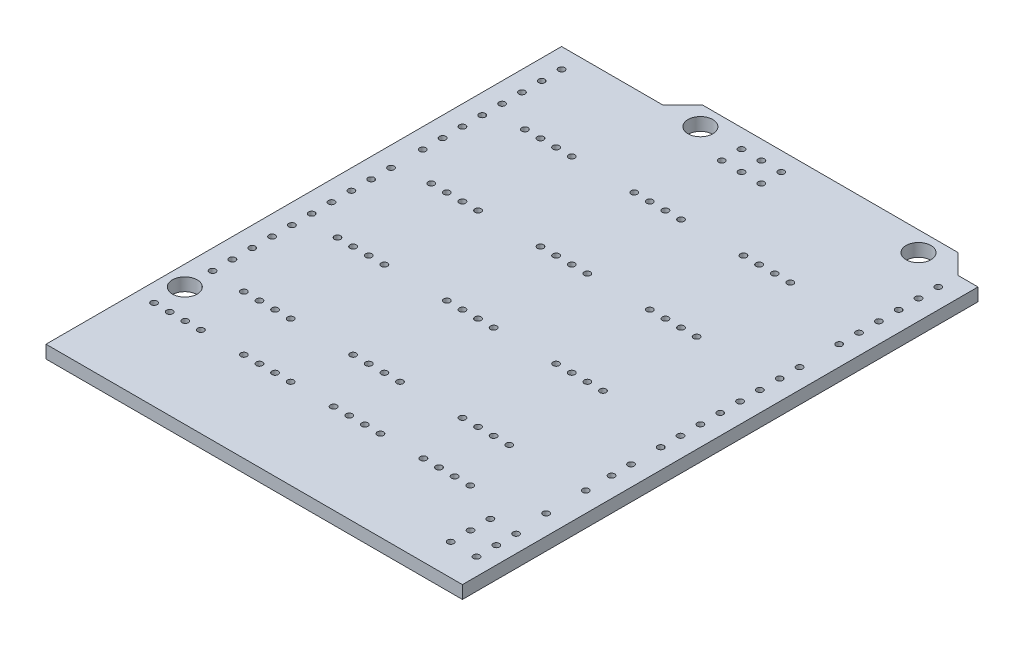
from build123d import *

# Parameters (mm, degrees)
SKETCH1_R                             = 1.5875
BOSS_EXTRUDE1_DEPTH                   = 1.65
SKETCH2_R                             = 0.4
CUT_EXTRUDE1_DEPTH                    = 1.65
SKETCH3_R                             = 0.4
CUT_EXTRUDE2_DEPTH                    = 1.65
LPATTERN1_COUNT                       = 15
LPATTERN1_PITCH                       = 2.54
SKETCH4_R                             = 0.4
CUT_EXTRUDE3_DEPTH                    = 1.65
LPATTERN2_COUNT                       = 10
LPATTERN2_PITCH                       = 2.54
LPATTERN3_COUNT                       = 8
LPATTERN3_PITCH                       = 2.54
SKETCH5_R                             = 0.4
CUT_EXTRUDE4_DEPTH                    = 10
ESQUISSE1_R                           = 0.4
ENL_V_MAT_EXTRU_1_DEPTH               = 10
R_P_TITION_LIN_AIRE1_COUNT            = 4
R_P_TITION_LIN_AIRE1_PITCH            = 2
R_P_TITION_LIN_AIRE1_COUNT_DIR2       = 4
R_P_TITION_LIN_AIRE1_PITCH_DIR2       = 11.5
ESQUISSE2_R                           = 0.4
ENL_V_MAT_EXTRU_2_DEPTH               = 10
R_P_TITION_LIN_AIRE2_COUNT            = 4
R_P_TITION_LIN_AIRE2_PITCH            = 2
R_P_TITION_LIN_AIRE2_COUNT_DIR2       = 3
R_P_TITION_LIN_AIRE2_PITCH_DIR2       = 14
R_P_TITION_LIN_AIRE3_COUNT            = 4
R_P_TITION_LIN_AIRE3_PITCH            = 12
R_P_TITION_LIN_AIRE3_COPY_1_SKETCH_R  = 0.4
R_P_TITION_LIN_AIRE3_COPY_1_DEPTH     = 10
R_P_TITION_LIN_AIRE3_COPY_2_SKETCH_R  = 0.4
R_P_TITION_LIN_AIRE3_COPY_2_DEPTH     = 10
R_P_TITION_LIN_AIRE3_COPY_3_SKETCH_R  = 0.4
R_P_TITION_LIN_AIRE3_COPY_3_DEPTH     = 10
R_P_TITION_LIN_AIRE3_COPY_4_SKETCH_R  = 0.4
R_P_TITION_LIN_AIRE3_COPY_4_DEPTH     = 10
R_P_TITION_LIN_AIRE3_COPY_5_SKETCH_R  = 0.4
R_P_TITION_LIN_AIRE3_COPY_5_DEPTH     = 10
R_P_TITION_LIN_AIRE3_COPY_6_SKETCH_R  = 0.4
R_P_TITION_LIN_AIRE3_COPY_6_DEPTH     = 10
R_P_TITION_LIN_AIRE3_COPY_7_SKETCH_R  = 0.4
R_P_TITION_LIN_AIRE3_COPY_7_DEPTH     = 10
R_P_TITION_LIN_AIRE3_COPY_8_SKETCH_R  = 0.4
R_P_TITION_LIN_AIRE3_COPY_8_DEPTH     = 10
R_P_TITION_LIN_AIRE3_COPY_9_SKETCH_R  = 0.4
R_P_TITION_LIN_AIRE3_COPY_9_DEPTH     = 10
R_P_TITION_LIN_AIRE3_COPY_10_SKETCH_R = 0.4
R_P_TITION_LIN_AIRE3_COPY_10_DEPTH    = 10
R_P_TITION_LIN_AIRE3_COPY_11_SKETCH_R = 0.4
R_P_TITION_LIN_AIRE3_COPY_11_DEPTH    = 10
R_P_TITION_LIN_AIRE3_COPY_12_SKETCH_R = 0.4
R_P_TITION_LIN_AIRE3_COPY_12_DEPTH    = 10
R_P_TITION_LIN_AIRE3_COPY_13_SKETCH_R = 0.4
R_P_TITION_LIN_AIRE3_COPY_13_DEPTH    = 10
R_P_TITION_LIN_AIRE3_COPY_14_SKETCH_R = 0.4
R_P_TITION_LIN_AIRE3_COPY_14_DEPTH    = 10
R_P_TITION_LIN_AIRE3_COPY_15_SKETCH_R = 0.4
R_P_TITION_LIN_AIRE3_COPY_15_DEPTH    = 10
R_P_TITION_LIN_AIRE3_COPY_16_SKETCH_R = 0.4
R_P_TITION_LIN_AIRE3_COPY_16_DEPTH    = 10
R_P_TITION_LIN_AIRE3_COPY_17_SKETCH_R = 0.4
R_P_TITION_LIN_AIRE3_COPY_17_DEPTH    = 10
R_P_TITION_LIN_AIRE3_COPY_18_SKETCH_R = 0.4
R_P_TITION_LIN_AIRE3_COPY_18_DEPTH    = 10
R_P_TITION_LIN_AIRE3_COPY_19_SKETCH_R = 0.4
R_P_TITION_LIN_AIRE3_COPY_19_DEPTH    = 10
R_P_TITION_LIN_AIRE3_COPY_20_SKETCH_R = 0.4
R_P_TITION_LIN_AIRE3_COPY_20_DEPTH    = 10
R_P_TITION_LIN_AIRE3_COPY_21_SKETCH_R = 0.4
R_P_TITION_LIN_AIRE3_COPY_21_DEPTH    = 10
R_P_TITION_LIN_AIRE3_COPY_22_SKETCH_R = 0.4
R_P_TITION_LIN_AIRE3_COPY_22_DEPTH    = 10
R_P_TITION_LIN_AIRE3_COPY_23_SKETCH_R = 0.4
R_P_TITION_LIN_AIRE3_COPY_23_DEPTH    = 10
R_P_TITION_LIN_AIRE3_COPY_24_SKETCH_R = 0.4
R_P_TITION_LIN_AIRE3_COPY_24_DEPTH    = 10
R_P_TITION_LIN_AIRE3_COPY_25_SKETCH_R = 0.4
R_P_TITION_LIN_AIRE3_COPY_25_DEPTH    = 10
R_P_TITION_LIN_AIRE3_COPY_26_SKETCH_R = 0.4
R_P_TITION_LIN_AIRE3_COPY_26_DEPTH    = 10
R_P_TITION_LIN_AIRE3_COPY_27_SKETCH_R = 0.4
R_P_TITION_LIN_AIRE3_COPY_27_DEPTH    = 10
R_P_TITION_LIN_AIRE3_COPY_28_SKETCH_R = 0.4
R_P_TITION_LIN_AIRE3_COPY_28_DEPTH    = 10
R_P_TITION_LIN_AIRE3_COPY_29_SKETCH_R = 0.4
R_P_TITION_LIN_AIRE3_COPY_29_DEPTH    = 10
R_P_TITION_LIN_AIRE3_COPY_30_SKETCH_R = 0.4
R_P_TITION_LIN_AIRE3_COPY_30_DEPTH    = 10
R_P_TITION_LIN_AIRE3_COPY_31_SKETCH_R = 0.4
R_P_TITION_LIN_AIRE3_COPY_31_DEPTH    = 10
R_P_TITION_LIN_AIRE3_COPY_32_SKETCH_R = 0.4
R_P_TITION_LIN_AIRE3_COPY_32_DEPTH    = 10
R_P_TITION_LIN_AIRE3_COPY_33_SKETCH_R = 0.4
R_P_TITION_LIN_AIRE3_COPY_33_DEPTH    = 10


with BuildPart() as part:
    # Sketch1 → Boss-Extrude1 (new body)
    with BuildSketch(Plane(origin=(0, 0, 0), x_dir=(1, 0, 0), z_dir=(0, 1, 0))):
        Polygon((0, 0), (-53.34, 0), (-53.34, 66.04), (-40.386, 66.04), (-37.846, 68.58), (-5.08, 68.58), (-2.54, 66.04), (0, 66.04), align=None)
        with Locations(Location((-7.62, 66.04, 0), (0, 0, 270))):  # turned: the seam where the file's is
            Circle(SKETCH1_R, mode=Mode.SUBTRACT)
        with Locations(Location((-35.56, 66.04, 0), (0, 0, 270))):  # turned: the seam where the file's is
            Circle(SKETCH1_R, mode=Mode.SUBTRACT)
        with Locations(Location((-50.8, 15.24, 0), (0, 0, 270))):  # turned: the seam where the file's is
            Circle(SKETCH1_R, mode=Mode.SUBTRACT)
    extrude(amount=-BOSS_EXTRUDE1_DEPTH)

    # Sketch2 → Cut-Extrude1 (cut)
    with BuildSketch(Plane(origin=(0, 0, 0), x_dir=(1, 0, 0), z_dir=(0, 1, 0))):
        with Locations(Location((-2.54, 27.94, 0), (0, 0, 270))):  # turned: the seam where the file's is
            Circle(SKETCH2_R)
    cut_extrude1 = extrude(amount=-CUT_EXTRUDE1_DEPTH, mode=Mode.SUBTRACT)

    # Sketch3 → Cut-Extrude2 (cut)
    with BuildSketch(Plane(origin=(0, 0, 0), x_dir=(1, 0, 0), z_dir=(0, 1, 0))):
        with Locations(Location((-50.8, 18.796, 0), (0, 0, 270))):  # turned: the seam where the file's is
            Circle(SKETCH3_R)
    cut_extrude2 = extrude(amount=-CUT_EXTRUDE2_DEPTH, mode=Mode.SUBTRACT)

    # LPattern1: Cut-Extrude1 ×15, 1 skipped
    with Locations(*[(0, 0, -i * LPATTERN1_PITCH) for i in range(1, LPATTERN1_COUNT) if i not in (8,)]):
        add(cut_extrude1, mode=Mode.SUBTRACT)

    # Sketch4 → Cut-Extrude3 (cut)
    with BuildSketch(Plane(origin=(0, 0, 0), x_dir=(1, 0, 0), z_dir=(0, 1, 0))):
        with Locations(Location((-50.8, 45.72, 0), (0, 0, 270))):  # turned: the seam where the file's is
            Circle(SKETCH4_R)
    cut_extrude3 = extrude(amount=-CUT_EXTRUDE3_DEPTH, mode=Mode.SUBTRACT)

    # LPattern2: Cut-Extrude2 ×10
    with Locations(*[(0, 0, -i * LPATTERN2_PITCH) for i in range(1, LPATTERN2_COUNT)]):
        add(cut_extrude2, mode=Mode.SUBTRACT)

    # LPattern3: Cut-Extrude3 ×8
    with Locations(*[(0, 0, -i * LPATTERN3_PITCH) for i in range(1, LPATTERN3_COUNT)]):
        add(cut_extrude3, mode=Mode.SUBTRACT)

    # Sketch5 → Cut-Extrude4 (cut)
    with BuildSketch(Plane(origin=(0, 0, 0), x_dir=(1, 0, 0), z_dir=(0, 1, 0))):
        with Locations(Location((-30.43, 66.18, 0), (0, 0, 270))):  # turned: the seam where the file's is
            Circle(SKETCH5_R)
        with Locations(Location((-27.89, 66.18, 0), (0, 0, 270))):  # turned: the seam where the file's is
            Circle(SKETCH5_R)
        with Locations(Location((-25.35, 66.18, 0), (0, 0, 270))):  # turned: the seam where the file's is
            Circle(SKETCH5_R)
        with Locations(Location((-25.35, 63.64, 0), (0, 0, 270))):  # turned: the seam where the file's is
            Circle(SKETCH5_R)
        with Locations(Location((-27.89, 63.64, 0), (0, 0, 270))):  # turned: the seam where the file's is
            Circle(SKETCH5_R)
        with Locations(Location((-30.43, 63.64, 0), (0, 0, 270))):  # turned: the seam where the file's is
            Circle(SKETCH5_R)
        with Locations(Location((-5.5, 4, 0), (0, 0, 270))):  # turned: the seam where the file's is
            Circle(SKETCH5_R)
        with Locations(Location((-5.5, 6.54, 0), (0, 0, 270))):  # turned: the seam where the file's is
            Circle(SKETCH5_R)
        with Locations(Location((-5.5, 9.08, 0), (0, 0, 270))):  # turned: the seam where the file's is
            Circle(SKETCH5_R)
        with Locations(Location((-2.2, 9.08, 0), (0, 0, 270))):  # turned: the seam where the file's is
            Circle(SKETCH5_R)
        with Locations(Location((-2.2, 6.54, 0), (0, 0, 270))):  # turned: the seam where the file's is
            Circle(SKETCH5_R)
        with Locations(Location((-2.2, 4, 0), (0, 0, 270))):  # turned: the seam where the file's is
            Circle(SKETCH5_R)
        with Locations(Location((-2.54, 24.14, 0), (0, 0, 270))):  # turned: the seam where the file's is
            Circle(SKETCH5_R)
        with Locations(Location((-2.54, 21.64, 0), (0, 0, 270))):  # turned: the seam where the file's is
            Circle(SKETCH5_R)
        with Locations(Location((-2.54, 18.34, 0), (0, 0, 270))):  # turned: the seam where the file's is
            Circle(SKETCH5_R)
        with Locations(Location((-2.54, 13.26, 0), (0, 0, 270))):  # turned: the seam where the file's is
            Circle(SKETCH5_R)
    extrude(amount=-CUT_EXTRUDE4_DEPTH, mode=Mode.SUBTRACT)

    # Esquisse1 → Enlèv. mat.-Extru.1 (cut)
    with BuildSketch(Plane.XZ.offset(1.65)):
        with Locations(Location((-10.5, -11.5, 0), (0, 0, 270))):  # turned: the seam where the file's is
            Circle(ESQUISSE1_R)
    enl_v_mat_extru_1 = extrude(amount=-ENL_V_MAT_EXTRU_1_DEPTH, mode=Mode.SUBTRACT)

    # Répétition linéaire1: Enl_v. mat.-Extru.1 4 × 4
    with Locations(*[Vector(-1, 0, 0) * (i * R_P_TITION_LIN_AIRE1_PITCH) + Vector(-1, 0, 0) * (j * R_P_TITION_LIN_AIRE1_PITCH_DIR2) for i in range(R_P_TITION_LIN_AIRE1_COUNT) for j in range(R_P_TITION_LIN_AIRE1_COUNT_DIR2) if (i, j) != (0, 0)]):
        add(enl_v_mat_extru_1, mode=Mode.SUBTRACT)

    # Esquisse2 → Enlèv. mat.-Extru.2 (cut)
    with BuildSketch(Plane.XZ.offset(1.65)):
        with Locations(Location((-12.5, -18.5, 0), (0, 0, 270))):  # turned: the seam where the file's is
            Circle(ESQUISSE2_R)
    enl_v_mat_extru_2 = extrude(amount=-ENL_V_MAT_EXTRU_2_DEPTH, mode=Mode.SUBTRACT)

    # Répétition linéaire2: Enl_v. mat.-Extru.2 4 × 3
    with Locations(*[Vector(-1, 0, 0) * (i * R_P_TITION_LIN_AIRE2_PITCH) + Vector(-1, 0, 0) * (j * R_P_TITION_LIN_AIRE2_PITCH_DIR2) for i in range(R_P_TITION_LIN_AIRE2_COUNT) for j in range(R_P_TITION_LIN_AIRE2_COUNT_DIR2) if (i, j) != (0, 0)]):
        add(enl_v_mat_extru_2, mode=Mode.SUBTRACT)

    # Répétition linéaire3: Enlèv. mat.-Extru.2 ×4
    with Locations(*[(0, 0, -i * R_P_TITION_LIN_AIRE3_PITCH) for i in range(1, R_P_TITION_LIN_AIRE3_COUNT)]):
        add(enl_v_mat_extru_2, mode=Mode.SUBTRACT)

    # Répétition linéaire3 copy 1 sketch → Répétition linéaire3 copy 1 (cut)
    with BuildSketch(Plane(origin=(-14, -1.65, -12), x_dir=(1, 0, 0), z_dir=(0, -1, 0))):
        with Locations(Location((-12.5, -18.5, 0), (0, 0, 270))):  # turned: the seam where the file's is
            Circle(R_P_TITION_LIN_AIRE3_COPY_1_SKETCH_R)
    extrude(amount=-R_P_TITION_LIN_AIRE3_COPY_1_DEPTH, mode=Mode.SUBTRACT)

    # Répétition linéaire3 copy 2 sketch → Répétition linéaire3 copy 2 (cut)
    with BuildSketch(Plane(origin=(-14, -1.65, -24), x_dir=(1, 0, 0), z_dir=(0, -1, 0))):
        with Locations(Location((-12.5, -18.5, 0), (0, 0, 270))):  # turned: the seam where the file's is
            Circle(R_P_TITION_LIN_AIRE3_COPY_2_SKETCH_R)
    extrude(amount=-R_P_TITION_LIN_AIRE3_COPY_2_DEPTH, mode=Mode.SUBTRACT)

    # Répétition linéaire3 copy 3 sketch → Répétition linéaire3 copy 3 (cut)
    with BuildSketch(Plane(origin=(-14, -1.65, -36), x_dir=(1, 0, 0), z_dir=(0, -1, 0))):
        with Locations(Location((-12.5, -18.5, 0), (0, 0, 270))):  # turned: the seam where the file's is
            Circle(R_P_TITION_LIN_AIRE3_COPY_3_SKETCH_R)
    extrude(amount=-R_P_TITION_LIN_AIRE3_COPY_3_DEPTH, mode=Mode.SUBTRACT)

    # Répétition linéaire3 copy 4 sketch → Répétition linéaire3 copy 4 (cut)
    with BuildSketch(Plane(origin=(-28, -1.65, -12), x_dir=(1, 0, 0), z_dir=(0, -1, 0))):
        with Locations(Location((-12.5, -18.5, 0), (0, 0, 270))):  # turned: the seam where the file's is
            Circle(R_P_TITION_LIN_AIRE3_COPY_4_SKETCH_R)
    extrude(amount=-R_P_TITION_LIN_AIRE3_COPY_4_DEPTH, mode=Mode.SUBTRACT)

    # Répétition linéaire3 copy 5 sketch → Répétition linéaire3 copy 5 (cut)
    with BuildSketch(Plane(origin=(-28, -1.65, -24), x_dir=(1, 0, 0), z_dir=(0, -1, 0))):
        with Locations(Location((-12.5, -18.5, 0), (0, 0, 270))):  # turned: the seam where the file's is
            Circle(R_P_TITION_LIN_AIRE3_COPY_5_SKETCH_R)
    extrude(amount=-R_P_TITION_LIN_AIRE3_COPY_5_DEPTH, mode=Mode.SUBTRACT)

    # Répétition linéaire3 copy 6 sketch → Répétition linéaire3 copy 6 (cut)
    with BuildSketch(Plane(origin=(-28, -1.65, -36), x_dir=(1, 0, 0), z_dir=(0, -1, 0))):
        with Locations(Location((-12.5, -18.5, 0), (0, 0, 270))):  # turned: the seam where the file's is
            Circle(R_P_TITION_LIN_AIRE3_COPY_6_SKETCH_R)
    extrude(amount=-R_P_TITION_LIN_AIRE3_COPY_6_DEPTH, mode=Mode.SUBTRACT)

    # Répétition linéaire3 copy 7 sketch → Répétition linéaire3 copy 7 (cut)
    with BuildSketch(Plane(origin=(-2, -1.65, -12), x_dir=(1, 0, 0), z_dir=(0, -1, 0))):
        with Locations(Location((-12.5, -18.5, 0), (0, 0, 270))):  # turned: the seam where the file's is
            Circle(R_P_TITION_LIN_AIRE3_COPY_7_SKETCH_R)
    extrude(amount=-R_P_TITION_LIN_AIRE3_COPY_7_DEPTH, mode=Mode.SUBTRACT)

    # Répétition linéaire3 copy 8 sketch → Répétition linéaire3 copy 8 (cut)
    with BuildSketch(Plane(origin=(-2, -1.65, -24), x_dir=(1, 0, 0), z_dir=(0, -1, 0))):
        with Locations(Location((-12.5, -18.5, 0), (0, 0, 270))):  # turned: the seam where the file's is
            Circle(R_P_TITION_LIN_AIRE3_COPY_8_SKETCH_R)
    extrude(amount=-R_P_TITION_LIN_AIRE3_COPY_8_DEPTH, mode=Mode.SUBTRACT)

    # Répétition linéaire3 copy 9 sketch → Répétition linéaire3 copy 9 (cut)
    with BuildSketch(Plane(origin=(-2, -1.65, -36), x_dir=(1, 0, 0), z_dir=(0, -1, 0))):
        with Locations(Location((-12.5, -18.5, 0), (0, 0, 270))):  # turned: the seam where the file's is
            Circle(R_P_TITION_LIN_AIRE3_COPY_9_SKETCH_R)
    extrude(amount=-R_P_TITION_LIN_AIRE3_COPY_9_DEPTH, mode=Mode.SUBTRACT)

    # Répétition linéaire3 copy 10 sketch → Répétition linéaire3 copy 10 (cut)
    with BuildSketch(Plane(origin=(-16, -1.65, -12), x_dir=(1, 0, 0), z_dir=(0, -1, 0))):
        with Locations(Location((-12.5, -18.5, 0), (0, 0, 270))):  # turned: the seam where the file's is
            Circle(R_P_TITION_LIN_AIRE3_COPY_10_SKETCH_R)
    extrude(amount=-R_P_TITION_LIN_AIRE3_COPY_10_DEPTH, mode=Mode.SUBTRACT)

    # Répétition linéaire3 copy 11 sketch → Répétition linéaire3 copy 11 (cut)
    with BuildSketch(Plane(origin=(-16, -1.65, -24), x_dir=(1, 0, 0), z_dir=(0, -1, 0))):
        with Locations(Location((-12.5, -18.5, 0), (0, 0, 270))):  # turned: the seam where the file's is
            Circle(R_P_TITION_LIN_AIRE3_COPY_11_SKETCH_R)
    extrude(amount=-R_P_TITION_LIN_AIRE3_COPY_11_DEPTH, mode=Mode.SUBTRACT)

    # Répétition linéaire3 copy 12 sketch → Répétition linéaire3 copy 12 (cut)
    with BuildSketch(Plane(origin=(-16, -1.65, -36), x_dir=(1, 0, 0), z_dir=(0, -1, 0))):
        with Locations(Location((-12.5, -18.5, 0), (0, 0, 270))):  # turned: the seam where the file's is
            Circle(R_P_TITION_LIN_AIRE3_COPY_12_SKETCH_R)
    extrude(amount=-R_P_TITION_LIN_AIRE3_COPY_12_DEPTH, mode=Mode.SUBTRACT)

    # Répétition linéaire3 copy 13 sketch → Répétition linéaire3 copy 13 (cut)
    with BuildSketch(Plane(origin=(-30, -1.65, -12), x_dir=(1, 0, 0), z_dir=(0, -1, 0))):
        with Locations(Location((-12.5, -18.5, 0), (0, 0, 270))):  # turned: the seam where the file's is
            Circle(R_P_TITION_LIN_AIRE3_COPY_13_SKETCH_R)
    extrude(amount=-R_P_TITION_LIN_AIRE3_COPY_13_DEPTH, mode=Mode.SUBTRACT)

    # Répétition linéaire3 copy 14 sketch → Répétition linéaire3 copy 14 (cut)
    with BuildSketch(Plane(origin=(-30, -1.65, -24), x_dir=(1, 0, 0), z_dir=(0, -1, 0))):
        with Locations(Location((-12.5, -18.5, 0), (0, 0, 270))):  # turned: the seam where the file's is
            Circle(R_P_TITION_LIN_AIRE3_COPY_14_SKETCH_R)
    extrude(amount=-R_P_TITION_LIN_AIRE3_COPY_14_DEPTH, mode=Mode.SUBTRACT)

    # Répétition linéaire3 copy 15 sketch → Répétition linéaire3 copy 15 (cut)
    with BuildSketch(Plane(origin=(-30, -1.65, -36), x_dir=(1, 0, 0), z_dir=(0, -1, 0))):
        with Locations(Location((-12.5, -18.5, 0), (0, 0, 270))):  # turned: the seam where the file's is
            Circle(R_P_TITION_LIN_AIRE3_COPY_15_SKETCH_R)
    extrude(amount=-R_P_TITION_LIN_AIRE3_COPY_15_DEPTH, mode=Mode.SUBTRACT)

    # Répétition linéaire3 copy 16 sketch → Répétition linéaire3 copy 16 (cut)
    with BuildSketch(Plane(origin=(-4, -1.65, -12), x_dir=(1, 0, 0), z_dir=(0, -1, 0))):
        with Locations(Location((-12.5, -18.5, 0), (0, 0, 270))):  # turned: the seam where the file's is
            Circle(R_P_TITION_LIN_AIRE3_COPY_16_SKETCH_R)
    extrude(amount=-R_P_TITION_LIN_AIRE3_COPY_16_DEPTH, mode=Mode.SUBTRACT)

    # Répétition linéaire3 copy 17 sketch → Répétition linéaire3 copy 17 (cut)
    with BuildSketch(Plane(origin=(-4, -1.65, -24), x_dir=(1, 0, 0), z_dir=(0, -1, 0))):
        with Locations(Location((-12.5, -18.5, 0), (0, 0, 270))):  # turned: the seam where the file's is
            Circle(R_P_TITION_LIN_AIRE3_COPY_17_SKETCH_R)
    extrude(amount=-R_P_TITION_LIN_AIRE3_COPY_17_DEPTH, mode=Mode.SUBTRACT)

    # Répétition linéaire3 copy 18 sketch → Répétition linéaire3 copy 18 (cut)
    with BuildSketch(Plane(origin=(-4, -1.65, -36), x_dir=(1, 0, 0), z_dir=(0, -1, 0))):
        with Locations(Location((-12.5, -18.5, 0), (0, 0, 270))):  # turned: the seam where the file's is
            Circle(R_P_TITION_LIN_AIRE3_COPY_18_SKETCH_R)
    extrude(amount=-R_P_TITION_LIN_AIRE3_COPY_18_DEPTH, mode=Mode.SUBTRACT)

    # Répétition linéaire3 copy 19 sketch → Répétition linéaire3 copy 19 (cut)
    with BuildSketch(Plane(origin=(-18, -1.65, -12), x_dir=(1, 0, 0), z_dir=(0, -1, 0))):
        with Locations(Location((-12.5, -18.5, 0), (0, 0, 270))):  # turned: the seam where the file's is
            Circle(R_P_TITION_LIN_AIRE3_COPY_19_SKETCH_R)
    extrude(amount=-R_P_TITION_LIN_AIRE3_COPY_19_DEPTH, mode=Mode.SUBTRACT)

    # Répétition linéaire3 copy 20 sketch → Répétition linéaire3 copy 20 (cut)
    with BuildSketch(Plane(origin=(-18, -1.65, -24), x_dir=(1, 0, 0), z_dir=(0, -1, 0))):
        with Locations(Location((-12.5, -18.5, 0), (0, 0, 270))):  # turned: the seam where the file's is
            Circle(R_P_TITION_LIN_AIRE3_COPY_20_SKETCH_R)
    extrude(amount=-R_P_TITION_LIN_AIRE3_COPY_20_DEPTH, mode=Mode.SUBTRACT)

    # Répétition linéaire3 copy 21 sketch → Répétition linéaire3 copy 21 (cut)
    with BuildSketch(Plane(origin=(-18, -1.65, -36), x_dir=(1, 0, 0), z_dir=(0, -1, 0))):
        with Locations(Location((-12.5, -18.5, 0), (0, 0, 270))):  # turned: the seam where the file's is
            Circle(R_P_TITION_LIN_AIRE3_COPY_21_SKETCH_R)
    extrude(amount=-R_P_TITION_LIN_AIRE3_COPY_21_DEPTH, mode=Mode.SUBTRACT)

    # Répétition linéaire3 copy 22 sketch → Répétition linéaire3 copy 22 (cut)
    with BuildSketch(Plane(origin=(-32, -1.65, -12), x_dir=(1, 0, 0), z_dir=(0, -1, 0))):
        with Locations(Location((-12.5, -18.5, 0), (0, 0, 270))):  # turned: the seam where the file's is
            Circle(R_P_TITION_LIN_AIRE3_COPY_22_SKETCH_R)
    extrude(amount=-R_P_TITION_LIN_AIRE3_COPY_22_DEPTH, mode=Mode.SUBTRACT)

    # Répétition linéaire3 copy 23 sketch → Répétition linéaire3 copy 23 (cut)
    with BuildSketch(Plane(origin=(-32, -1.65, -24), x_dir=(1, 0, 0), z_dir=(0, -1, 0))):
        with Locations(Location((-12.5, -18.5, 0), (0, 0, 270))):  # turned: the seam where the file's is
            Circle(R_P_TITION_LIN_AIRE3_COPY_23_SKETCH_R)
    extrude(amount=-R_P_TITION_LIN_AIRE3_COPY_23_DEPTH, mode=Mode.SUBTRACT)

    # Répétition linéaire3 copy 24 sketch → Répétition linéaire3 copy 24 (cut)
    with BuildSketch(Plane(origin=(-32, -1.65, -36), x_dir=(1, 0, 0), z_dir=(0, -1, 0))):
        with Locations(Location((-12.5, -18.5, 0), (0, 0, 270))):  # turned: the seam where the file's is
            Circle(R_P_TITION_LIN_AIRE3_COPY_24_SKETCH_R)
    extrude(amount=-R_P_TITION_LIN_AIRE3_COPY_24_DEPTH, mode=Mode.SUBTRACT)

    # Répétition linéaire3 copy 25 sketch → Répétition linéaire3 copy 25 (cut)
    with BuildSketch(Plane(origin=(-6, -1.65, -12), x_dir=(1, 0, 0), z_dir=(0, -1, 0))):
        with Locations(Location((-12.5, -18.5, 0), (0, 0, 270))):  # turned: the seam where the file's is
            Circle(R_P_TITION_LIN_AIRE3_COPY_25_SKETCH_R)
    extrude(amount=-R_P_TITION_LIN_AIRE3_COPY_25_DEPTH, mode=Mode.SUBTRACT)

    # Répétition linéaire3 copy 26 sketch → Répétition linéaire3 copy 26 (cut)
    with BuildSketch(Plane(origin=(-6, -1.65, -24), x_dir=(1, 0, 0), z_dir=(0, -1, 0))):
        with Locations(Location((-12.5, -18.5, 0), (0, 0, 270))):  # turned: the seam where the file's is
            Circle(R_P_TITION_LIN_AIRE3_COPY_26_SKETCH_R)
    extrude(amount=-R_P_TITION_LIN_AIRE3_COPY_26_DEPTH, mode=Mode.SUBTRACT)

    # Répétition linéaire3 copy 27 sketch → Répétition linéaire3 copy 27 (cut)
    with BuildSketch(Plane(origin=(-6, -1.65, -36), x_dir=(1, 0, 0), z_dir=(0, -1, 0))):
        with Locations(Location((-12.5, -18.5, 0), (0, 0, 270))):  # turned: the seam where the file's is
            Circle(R_P_TITION_LIN_AIRE3_COPY_27_SKETCH_R)
    extrude(amount=-R_P_TITION_LIN_AIRE3_COPY_27_DEPTH, mode=Mode.SUBTRACT)

    # Répétition linéaire3 copy 28 sketch → Répétition linéaire3 copy 28 (cut)
    with BuildSketch(Plane(origin=(-20, -1.65, -12), x_dir=(1, 0, 0), z_dir=(0, -1, 0))):
        with Locations(Location((-12.5, -18.5, 0), (0, 0, 270))):  # turned: the seam where the file's is
            Circle(R_P_TITION_LIN_AIRE3_COPY_28_SKETCH_R)
    extrude(amount=-R_P_TITION_LIN_AIRE3_COPY_28_DEPTH, mode=Mode.SUBTRACT)

    # Répétition linéaire3 copy 29 sketch → Répétition linéaire3 copy 29 (cut)
    with BuildSketch(Plane(origin=(-20, -1.65, -24), x_dir=(1, 0, 0), z_dir=(0, -1, 0))):
        with Locations(Location((-12.5, -18.5, 0), (0, 0, 270))):  # turned: the seam where the file's is
            Circle(R_P_TITION_LIN_AIRE3_COPY_29_SKETCH_R)
    extrude(amount=-R_P_TITION_LIN_AIRE3_COPY_29_DEPTH, mode=Mode.SUBTRACT)

    # Répétition linéaire3 copy 30 sketch → Répétition linéaire3 copy 30 (cut)
    with BuildSketch(Plane(origin=(-20, -1.65, -36), x_dir=(1, 0, 0), z_dir=(0, -1, 0))):
        with Locations(Location((-12.5, -18.5, 0), (0, 0, 270))):  # turned: the seam where the file's is
            Circle(R_P_TITION_LIN_AIRE3_COPY_30_SKETCH_R)
    extrude(amount=-R_P_TITION_LIN_AIRE3_COPY_30_DEPTH, mode=Mode.SUBTRACT)

    # Répétition linéaire3 copy 31 sketch → Répétition linéaire3 copy 31 (cut)
    with BuildSketch(Plane(origin=(-34, -1.65, -12), x_dir=(1, 0, 0), z_dir=(0, -1, 0))):
        with Locations(Location((-12.5, -18.5, 0), (0, 0, 270))):  # turned: the seam where the file's is
            Circle(R_P_TITION_LIN_AIRE3_COPY_31_SKETCH_R)
    extrude(amount=-R_P_TITION_LIN_AIRE3_COPY_31_DEPTH, mode=Mode.SUBTRACT)

    # Répétition linéaire3 copy 32 sketch → Répétition linéaire3 copy 32 (cut)
    with BuildSketch(Plane(origin=(-34, -1.65, -24), x_dir=(1, 0, 0), z_dir=(0, -1, 0))):
        with Locations(Location((-12.5, -18.5, 0), (0, 0, 270))):  # turned: the seam where the file's is
            Circle(R_P_TITION_LIN_AIRE3_COPY_32_SKETCH_R)
    extrude(amount=-R_P_TITION_LIN_AIRE3_COPY_32_DEPTH, mode=Mode.SUBTRACT)

    # Répétition linéaire3 copy 33 sketch → Répétition linéaire3 copy 33 (cut)
    with BuildSketch(Plane(origin=(-34, -1.65, -36), x_dir=(1, 0, 0), z_dir=(0, -1, 0))):
        with Locations(Location((-12.5, -18.5, 0), (0, 0, 270))):  # turned: the seam where the file's is
            Circle(R_P_TITION_LIN_AIRE3_COPY_33_SKETCH_R)
    extrude(amount=-R_P_TITION_LIN_AIRE3_COPY_33_DEPTH, mode=Mode.SUBTRACT)


solid = part.part
